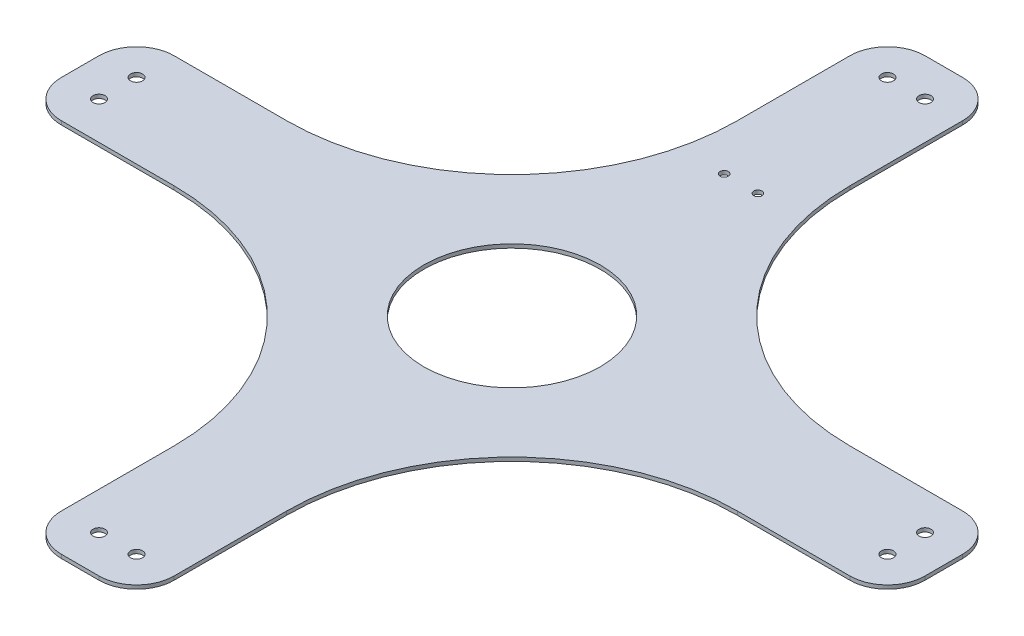
from build123d import *

# Parameters (mm, degrees)
BOSS_EXTRUDE1_DEPTH      = 0.5
M3_CLEARANCE_HOLE1_D     = 3.2
M3_CLEARANCE_HOLE1_DEPTH = 1
SKETCH5_R                = 23.5
CUT_EXTRUDE1_DEPTH       = 1
CUT_EXTRUDE1_DEPTH_BACK  = 2
M2_CLEARANCE_HOLE1_D     = 2.2
M2_CLEARANCE_HOLE1_DEPTH = 1


with BuildPart() as part:
    # Sketch1 → Boss-Extrude1 (new body, symmetric)
    with BuildSketch(Plane(origin=(0, 0, 0), x_dir=(1, 0, 0), z_dir=(0, 1, 0))):
        with BuildLine():
            Line((75, 15), (105, 15))
            ThreePointArc((105, 15), (112.071067812, 12.071067812), (115, 5))
            Line((115, 5), (115, -5))
            ThreePointArc((115, -5), (112.071067812, -12.071067812), (105, -15))
            Line((105, -15), (75, -15))
            ThreePointArc((75, -15), (32.573593129, -32.573593129), (15, -75))
            Line((15, -75), (15, -105))
            ThreePointArc((15, -105), (12.071067812, -112.071067812), (5, -115))
            Line((5, -115), (-5, -115))
            ThreePointArc((-5, -115), (-12.071067812, -112.071067812), (-15, -105))
            Line((-15, -105), (-15, -75))
            ThreePointArc((-15, -75), (-32.573593129, -32.573593129), (-75, -15))
            Line((-75, -15), (-105, -15))
            ThreePointArc((-105, -15), (-112.071067812, -12.071067812), (-115, -5))
            Line((-115, -5), (-115, 5))
            ThreePointArc((-115, 5), (-112.071067812, 12.071067812), (-105, 15))
            Line((-105, 15), (-75, 15))
            ThreePointArc((-75, 15), (-32.573593129, 32.573593129), (-15, 75))
            Line((-15, 75), (-15, 105))
            ThreePointArc((-15, 105), (-12.071067812, 112.071067812), (-5, 115))
            Line((-5, 115), (5, 115))
            ThreePointArc((5, 115), (12.071067812, 112.071067812), (15, 105))
            Line((15, 105), (15, 75))
            ThreePointArc((15, 75), (32.573593129, 32.573593129), (75, 15))
        make_face()
    extrude(amount=BOSS_EXTRUDE1_DEPTH, both=True)

    # M3 Clearance Hole1
    with Locations(Plane(origin=(0, 0.5, 0), x_dir=(1, 0, 0), z_dir=(0, 1, 0))):
        with Locations((-105, 5), (-105, -5), (-5, 105), (5, 105), (105, 5), (105, -5), (5, -105), (-5, -105)):
            Hole(M3_CLEARANCE_HOLE1_D / 2, depth=M3_CLEARANCE_HOLE1_DEPTH)

    # Sketch5 → Cut-Extrude1 (cut, two sides)
    with BuildSketch(Plane(origin=(0, 0.5, 0), x_dir=(1, 0, 0), z_dir=(0, 1, 0))) as cut_extrude1_sk:
        Circle(SKETCH5_R)
    extrude(amount=CUT_EXTRUDE1_DEPTH, mode=Mode.SUBTRACT)
    extrude(cut_extrude1_sk.sketch, amount=-CUT_EXTRUDE1_DEPTH_BACK, mode=Mode.SUBTRACT)

    # M2 Clearance Hole1
    with Locations(Plane(origin=(0, 0.5, 0), x_dir=(1, 0, 0), z_dir=(0, 1, 0))):
        with Locations((-4.5, 61), (4.5, 61)):
            Hole(M2_CLEARANCE_HOLE1_D / 2, depth=M2_CLEARANCE_HOLE1_DEPTH)


solid = part.part
